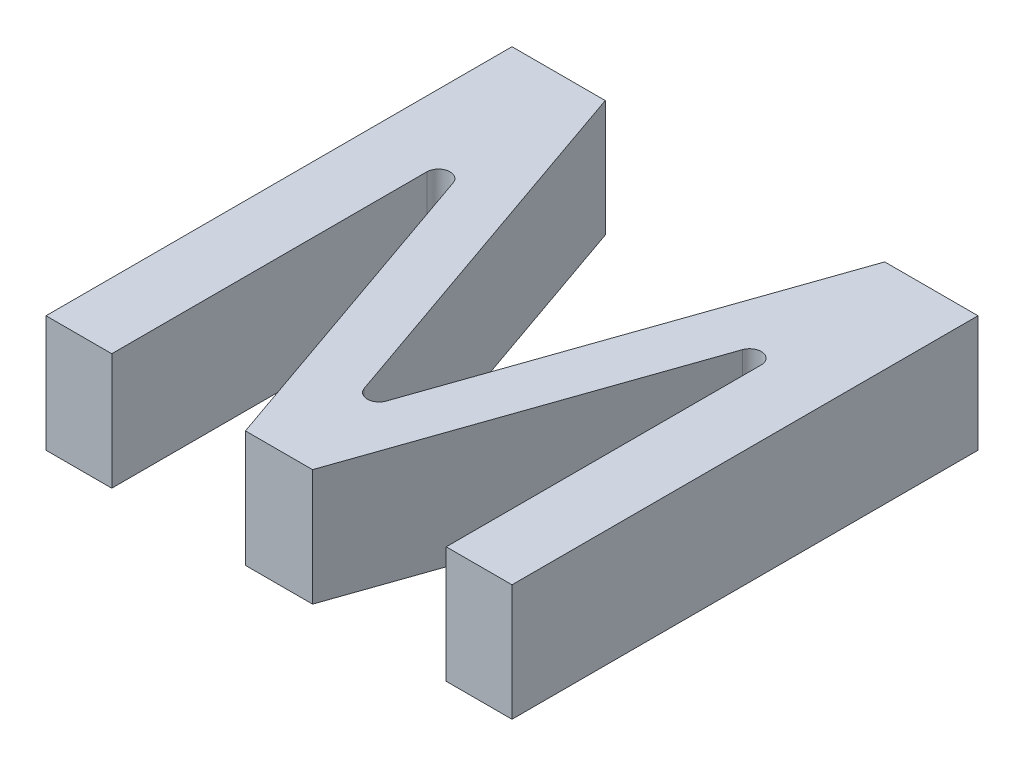
from build123d import *

# Parameters (mm, degrees)
BOSS_EXTRUDE1_DEPTH = 10
FILLET1_R           = 1


with BuildPart() as part:
    # Sketch1 → Boss-Extrude1 (new body)
    with BuildSketch(Plane(origin=(0, 0, 0), x_dir=(1, 0, 0), z_dir=(0, 1, 0))):
        Polygon((34.354251199, 32.954418358), (34.354251199, 0), (40, 0), (40, 40), (31.995376073, 40), (20, 5.546535934), (8.004623927, 40), (0, 40), (0, 0), (5.645748801, 0), (5.645748801, 32.954418358), (17.119214595, 0), (22.880785405, 0), align=None)
    extrude(amount=BOSS_EXTRUDE1_DEPTH)

    # Fillet1
    fillet1_edges = [part.edges().sort_by_distance(p)[0] for p in [
        (34.354251199, 5, -32.954418358),
        (5.645748801, 5, -32.954418358),
        (20, 5, -5.546535934),
    ]]
    fillet(fillet1_edges, radius=FILLET1_R)


solid = part.part
